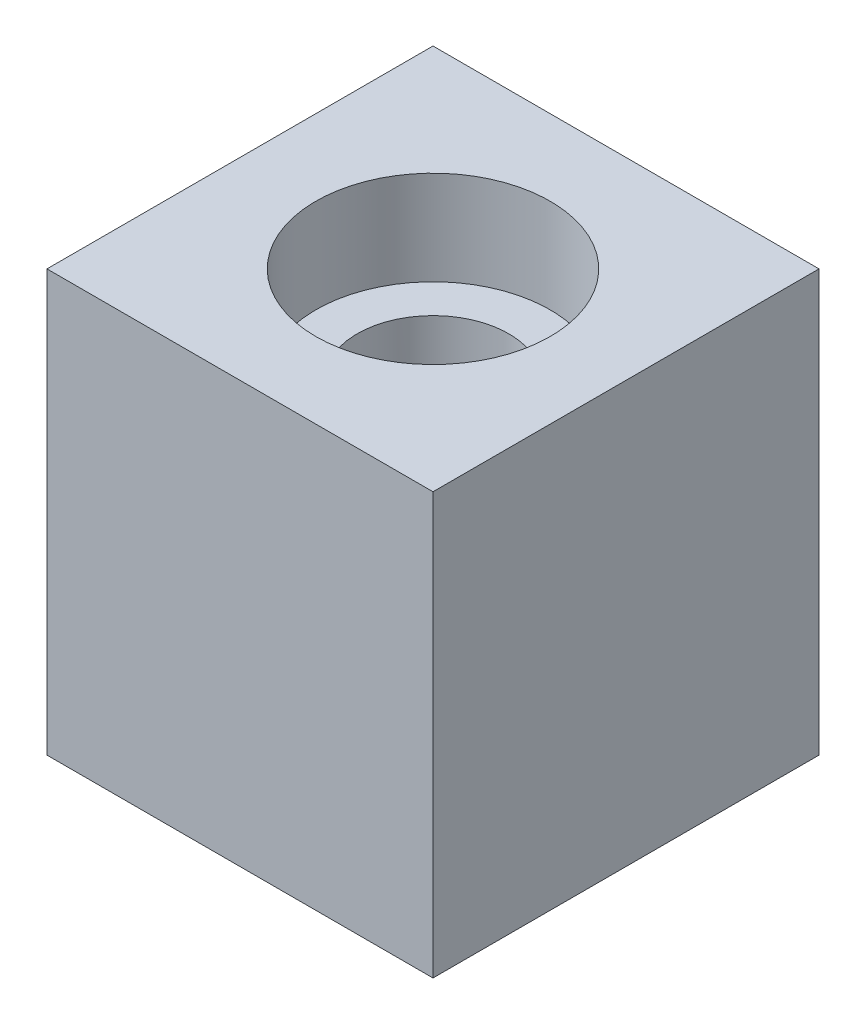
from build123d import *

# Parameters (mm, degrees)
SKETCH1_W           = 69.85
SKETCH1_H           = 69.85
BOSS_EXTRUDE1_DEPTH = 76.2
SKETCH2_R           = 13.716
CUT_EXTRUDE1_DEPTH  = 76.2
SKETCH4_R           = 21.209
CUT_EXTRUDE2_DEPTH  = 17.018
SKETCH5_R           = 21.209
CUT_EXTRUDE3_DEPTH  = 7.62


with BuildPart() as part:
    # Sketch1 → Boss-Extrude1 (new body)
    with BuildSketch(Plane(origin=(0, 0, 0), x_dir=(1, 0, 0), z_dir=(0, 1, 0))):
        with Locations((34.925, 34.925)):
            Rectangle(SKETCH1_W, SKETCH1_H)
    extrude(amount=BOSS_EXTRUDE1_DEPTH)

    # Sketch2 → Cut-Extrude1 (cut)
    with BuildSketch(Plane(origin=(0, 76.2, 0), x_dir=(1, 0, 0), z_dir=(0, 1, 0))):
        with Locations((34.925, 34.925)):
            Circle(SKETCH2_R)
    extrude(amount=-CUT_EXTRUDE1_DEPTH, mode=Mode.SUBTRACT)

    # Sketch4 → Cut-Extrude2 (cut)
    with BuildSketch(Plane(origin=(0, 76.2, 0), x_dir=(1, 0, 0), z_dir=(0, 1, 0))):
        with Locations((34.925, 34.925)):
            Circle(SKETCH4_R)
    extrude(amount=-CUT_EXTRUDE2_DEPTH, mode=Mode.SUBTRACT)

    # Sketch5 → Cut-Extrude3 (cut)
    with BuildSketch(Plane.XZ):
        with Locations((34.925, -34.925)):
            Circle(SKETCH5_R)
    extrude(amount=-CUT_EXTRUDE3_DEPTH, mode=Mode.SUBTRACT)


solid = part.part
